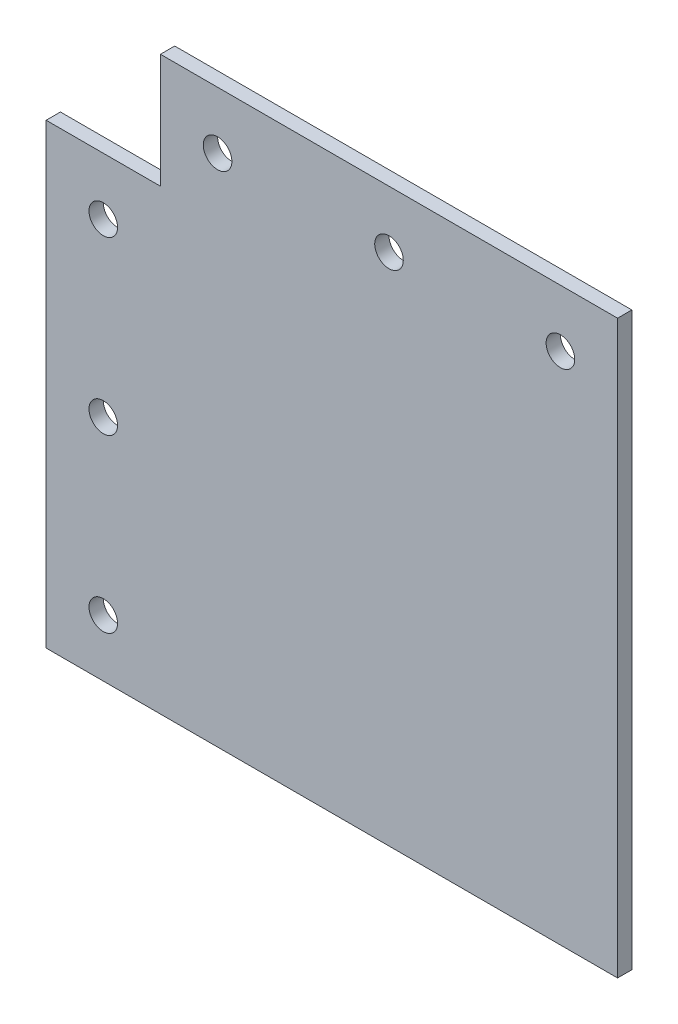
from build123d import *

# Parameters (mm, degrees)
SKETCH1_R           = 3.175
BOSS_EXTRUDE1_DEPTH = 3.175


with BuildPart() as part:
    # Sketch1 → Boss-Extrude1 (new body)
    with BuildSketch(Plane.XY):
        Polygon((0, 0), (127, 0), (127, 127), (25.4, 127), (25.4, 101.6), (0, 101.6), align=None)
        with Locations((12.7, 88.9)):
            Circle(SKETCH1_R, mode=Mode.SUBTRACT)
        with Locations((12.7, 50.8)):
            Circle(SKETCH1_R, mode=Mode.SUBTRACT)
        with Locations((12.7, 12.7)):
            Circle(SKETCH1_R, mode=Mode.SUBTRACT)
        with Locations((38.1, 114.3)):
            Circle(SKETCH1_R, mode=Mode.SUBTRACT)
        with Locations((76.2, 114.3)):
            Circle(SKETCH1_R, mode=Mode.SUBTRACT)
        with Locations((114.3, 114.3)):
            Circle(SKETCH1_R, mode=Mode.SUBTRACT)
    extrude(amount=BOSS_EXTRUDE1_DEPTH)


solid = part.part
